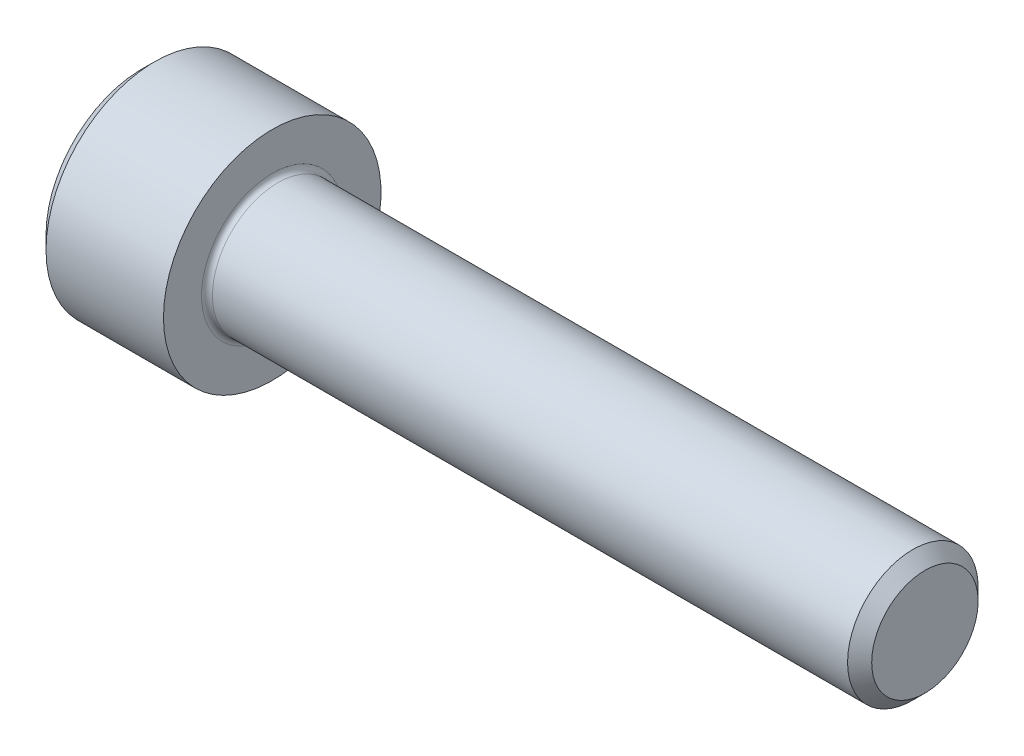
from build123d import *

# Parameters (mm, degrees)
FILLET1_R   = 0.25
HEX_2_DEPTH = 3


with BuildPart() as part:
    # BodySke → Base-Revolve (revolve)
    with BuildSketch(Plane.XY):
        Polygon((0, 0), (0, 4.4), (0.6, 5), (6, 5), (6, 3), (35.4455, 3), (36, 2.4455), (36, 0), align=None)
    revolve(axis=Axis((-31.75, 0, 0), (1, 0, 0)))

    # Fillet1
    fillet1_edges = [part.edges().sort_by_distance(p)[0] for p in [
        (6, -3, 0),
    ]]
    fillet(fillet1_edges, radius=FILLET1_R)

    # Sketch2 → Hex-PreBroach (revolve, cut)
    with BuildSketch(Plane.XY):
        Polygon((0, 2.542), (3, 2.542), (4.467624384, 0), (0, 0), align=None)
    revolve(axis=Axis((0, 0, 0), (1, 0, 0)), mode=Mode.SUBTRACT)

    # Sketch3 → Hex 2 (cut)
    with BuildSketch(Plane(origin=(0, 0, 0), x_dir=(0, 0.5, 0.866025404), z_dir=(-1, 0, 0))):
        Polygon((1.467624384, 2.542), (-1.467624384, 2.542), (-2.935248769, 0), (-1.467624384, -2.542), (1.467624384, -2.542), (2.935248769, 0), align=None)
    extrude(amount=-HEX_2_DEPTH, mode=Mode.SUBTRACT)


solid = part.part
